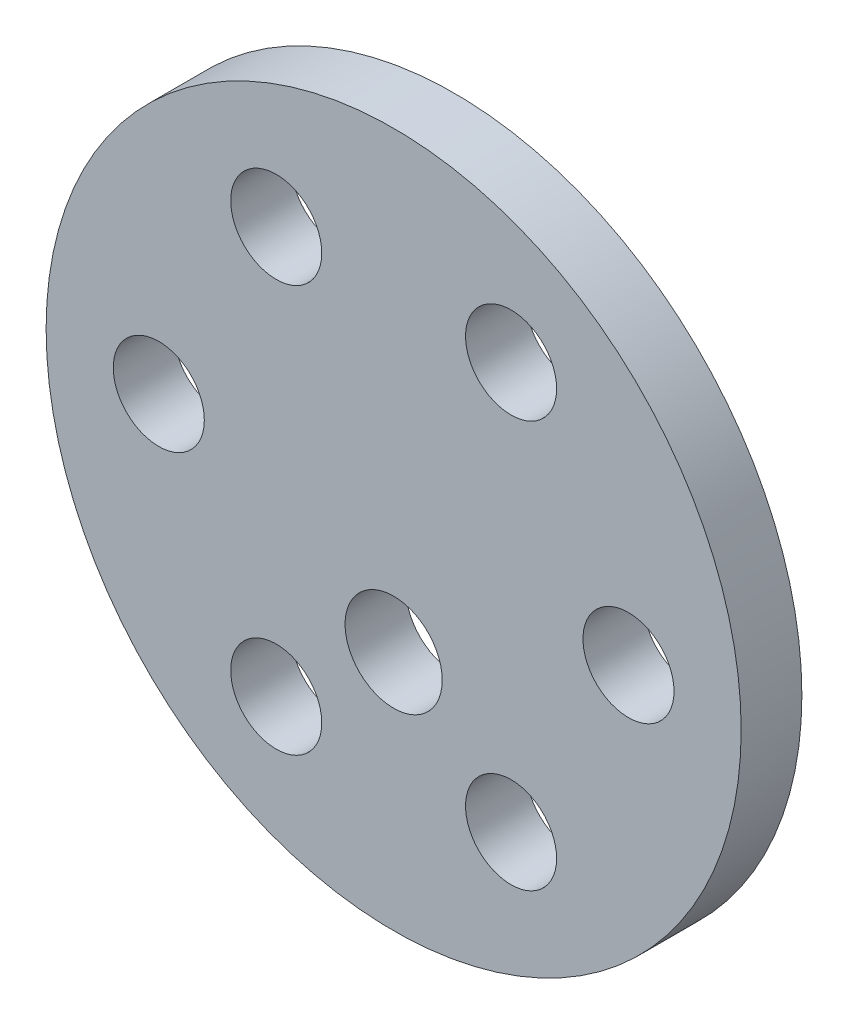
from build123d import *

# Parameters (mm, degrees)
SKETCH2_R           = 22.9
SKETCH2_R_2         = 3
SKETCH2_R_3         = 3.2
BOSS_EXTRUDE1_DEPTH = 4


with BuildPart() as part:
    # Sketch2 → Boss-Extrude1 (new body)
    with BuildSketch(Plane.XY):
        Circle(SKETCH2_R)
        with Locations((15.475, 0)):
            Circle(SKETCH2_R_2, mode=Mode.SUBTRACT)
        with Locations((7.7375, -13.401743124)):
            Circle(SKETCH2_R_2, mode=Mode.SUBTRACT)
        with Locations((-7.7375, -13.401743124)):
            Circle(SKETCH2_R_2, mode=Mode.SUBTRACT)
        with Locations((-15.475, 0)):
            Circle(SKETCH2_R_2, mode=Mode.SUBTRACT)
        with Locations((-7.7375, 13.401743124)):
            Circle(SKETCH2_R_2, mode=Mode.SUBTRACT)
        with Locations((7.7375, 13.401743124)):
            Circle(SKETCH2_R_2, mode=Mode.SUBTRACT)
        with Locations((0, -7)):
            Circle(SKETCH2_R_3, mode=Mode.SUBTRACT)
    extrude(amount=BOSS_EXTRUDE1_DEPTH)


solid = part.part
